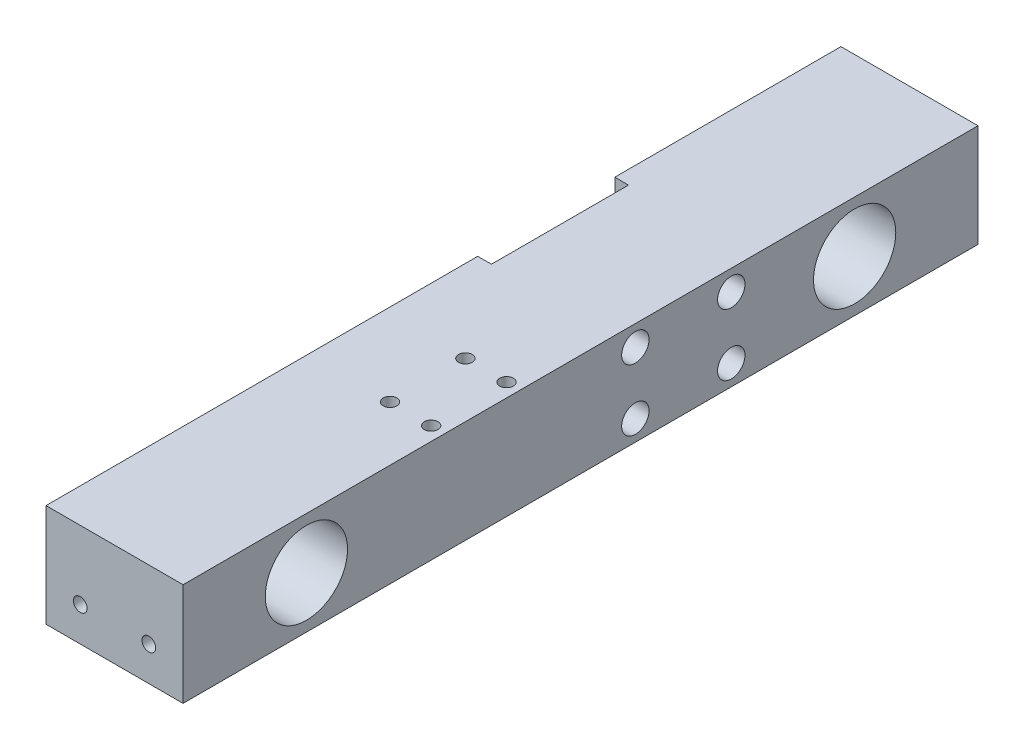
from build123d import *

# Parameters (mm, degrees)
SKETCH1_W           = 20
SKETCH1_H           = 15
BOSS_EXTRUDE1_DEPTH = 116
SKETCH1_5_R         = 1
CUT_EXTRUDE1_DEPTH  = 10
CUT_EXTRUDE2_START  = -10
SKETCH4_R           = 1
CUT_EXTRUDE2_DEPTH  = 10
SKETCH5_R           = 2.5
CUT_EXTRUDE3_DEPTH  = 119.663389468
SKETCH6_R           = 6
CUT_EXTRUDE4_DEPTH  = 119.663389468
SKETCH8_R           = 1
CUT_EXTRUDE5_DEPTH  = 119.663389468
SKETCH9_R           = 1.5
CUT_EXTRUDE6_DEPTH  = 5
SKETCH10_R          = 1
CUT_EXTRUDE7_DEPTH  = 119.663389468
SKETCH11_R          = 2
CUT_EXTRUDE8_DEPTH  = 5
SKETCH10_3_W        = 20
SKETCH10_3_H        = 15
SKETCH10_3_R        = 1
CUT_EXTRUDE9_DEPTH  = 2


with BuildPart() as part:
    # Sketch1 → Boss-Extrude1 (new body)
    with BuildSketch(Plane.XY):
        with Locations((10, 7.5)):
            Rectangle(SKETCH1_W, SKETCH1_H)
    extrude(amount=BOSS_EXTRUDE1_DEPTH)

    # Sketch1_5 → Cut-Extrude1 (cut)
    with BuildSketch(Plane.XY):
        with Locations((15, 5)):
            Circle(SKETCH1_5_R)
        with Locations((5, 5)):
            Circle(SKETCH1_5_R)
    extrude(amount=CUT_EXTRUDE1_DEPTH, mode=Mode.SUBTRACT)

    # Sketch4 → Cut-Extrude2 (cut)
    with BuildSketch(Plane.XY.offset(116).offset(CUT_EXTRUDE2_START)):
        with Locations((5, 5)):
            Circle(SKETCH4_R)
        with Locations((15, 5)):
            Circle(SKETCH4_R)
    extrude(amount=CUT_EXTRUDE2_DEPTH, mode=Mode.SUBTRACT)

    # Sketch5 → Cut-Extrude3 (cut, through all)
    with BuildSketch(Plane(origin=(20, 0, 0), x_dir=(0, 0, -1), z_dir=(1, 0, 0))):
        with Locations((-98, 7.5)):
            Circle(SKETCH5_R)
        with Locations((-18, 7.5)):
            Circle(SKETCH5_R)
    extrude(amount=-CUT_EXTRUDE3_DEPTH, mode=Mode.SUBTRACT)

    # Sketch6 → Cut-Extrude4 (cut, through all)
    with BuildSketch(Plane(origin=(20, 0, 0), x_dir=(0, 0, -1), z_dir=(1, 0, 0))):
        with Locations((-98, 7.5)):
            Circle(SKETCH6_R)
        with Locations((-18, 7.5)):
            Circle(SKETCH6_R)
    extrude(amount=-CUT_EXTRUDE4_DEPTH, mode=Mode.SUBTRACT)

    # Sketch8 → Cut-Extrude5 (cut, through all)
    with BuildSketch(Plane(origin=(0, 15, 0), x_dir=(1, 0, 0), z_dir=(0, 1, 0))):
        with Locations((12, -66.8)):
            Circle(SKETCH8_R)
        with Locations((18, -66.8)):
            Circle(SKETCH8_R)
        with Locations((18, -77.8)):
            Circle(SKETCH8_R)
        with Locations((12, -77.8)):
            Circle(SKETCH8_R)
    extrude(amount=-CUT_EXTRUDE5_DEPTH, mode=Mode.SUBTRACT)

    # Sketch9 → Cut-Extrude6 (cut)
    with BuildSketch(Plane(origin=(0, 0, 0), x_dir=(-1, 0, 0), z_dir=(0, -1, 0))):
        with Locations((-18, -66.8)):
            Circle(SKETCH9_R)
        with Locations((-18, -77.8)):
            Circle(SKETCH9_R)
        with Locations((-12, -77.8)):
            Circle(SKETCH9_R)
        with Locations((-12, -66.8)):
            Circle(SKETCH9_R)
    extrude(amount=-CUT_EXTRUDE6_DEPTH, mode=Mode.SUBTRACT)

    # Sketch10 → Cut-Extrude7 (cut, through all)
    with BuildSketch(Plane.ZY):
        with Locations((36, 12)):
            Circle(SKETCH10_R)
        with Locations((50, 12)):
            Circle(SKETCH10_R)
        with Locations((50, 3)):
            Circle(SKETCH10_R)
        with Locations((36, 3)):
            Circle(SKETCH10_R)
    extrude(amount=-CUT_EXTRUDE7_DEPTH, mode=Mode.SUBTRACT)

    # Sketch11 → Cut-Extrude8 (cut)
    with BuildSketch(Plane(origin=(20, 0, 0), x_dir=(0, 0, -1), z_dir=(1, 0, 0))):
        with Locations((-36, 12)):
            Circle(SKETCH11_R)
        with Locations((-36, 3)):
            Circle(SKETCH11_R)
        with Locations((-50, 3)):
            Circle(SKETCH11_R)
        with Locations((-50, 12)):
            Circle(SKETCH11_R)
    extrude(amount=-CUT_EXTRUDE8_DEPTH, mode=Mode.SUBTRACT)

    # Sketch10_3 → Cut-Extrude9 (cut)
    with BuildSketch(Plane.ZY):
        with Locations((43, 7.5)):
            Rectangle(SKETCH10_3_W, SKETCH10_3_H)
        with Locations((36, 3)):
            Circle(SKETCH10_3_R, mode=Mode.SUBTRACT)
        with Locations((36, 12)):
            Circle(SKETCH10_3_R, mode=Mode.SUBTRACT)
        with Locations((50, 3)):
            Circle(SKETCH10_3_R, mode=Mode.SUBTRACT)
        with Locations((50, 12)):
            Circle(SKETCH10_3_R, mode=Mode.SUBTRACT)
    extrude(amount=-CUT_EXTRUDE9_DEPTH, mode=Mode.SUBTRACT)


solid = part.part
